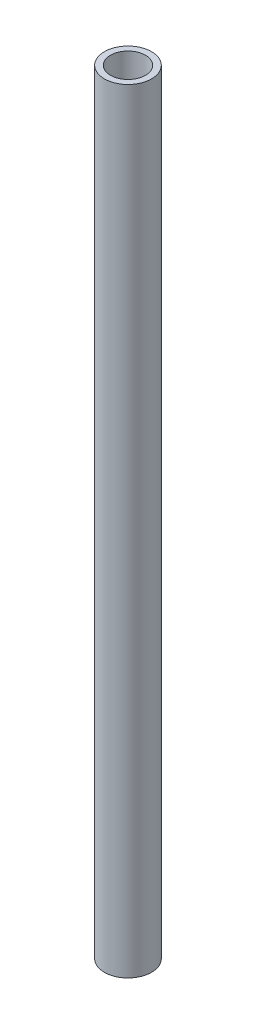
from build123d import *

# Parameters (mm, degrees)
SKETCH1_R           = 10.668
SKETCH1_R_2         = 7.8994
BOSS_EXTRUDE1_DEPTH = 350


with BuildPart() as part:
    # Sketch1 → Boss-Extrude1 (new body)
    with BuildSketch(Plane(origin=(0, 0, 0), x_dir=(1, 0, 0), z_dir=(0, 1, 0))):
        Circle(SKETCH1_R)
        Circle(SKETCH1_R_2, mode=Mode.SUBTRACT)
    extrude(amount=BOSS_EXTRUDE1_DEPTH)


solid = part.part
